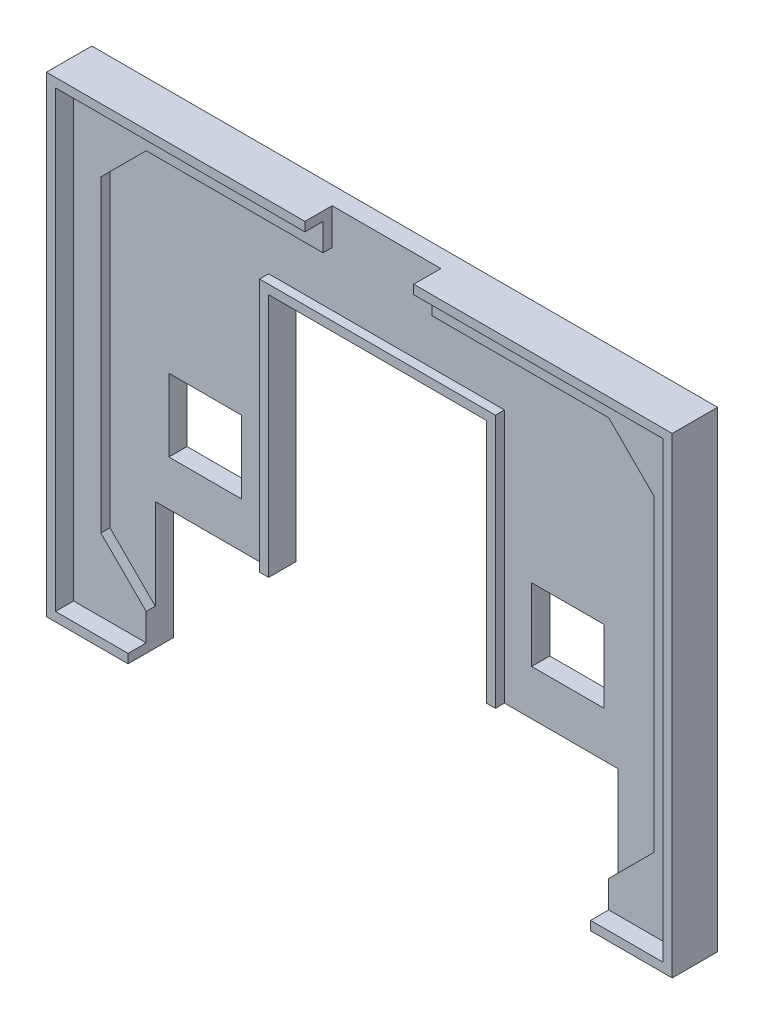
from build123d import *

# Parameters (mm, degrees)
SKICA1_W                    = 67
SKICA1_H                    = 50
P_IDAT_VYSUNUT_M1_DEPTH     = 3
ODEBRAT_VYSUNUT_M1_DEPTH    = 1
SKICA3_W                    = 8
SKICA3_H                    = 8
ODEBRAT_VYSUNUT_M2_DEPTH    = 4
VYSUNOUT_TENKOST_NN_1_DEPTH = 1
VYSUNOUT_TENKOST_NN_2_DEPTH = 5
SKICA6_W                    = 12
SKICA6_H                    = 4
ODEBRAT_VYSUNUT_M3_DEPTH    = 4
ODEBRAT_VYSUNUT_M4_DEPTH    = 1
P_IDAT_START                = -1
SKICA8_W                    = 0.8
SKICA8_H                    = 0.8
P_IDAT_VYSUNUT_M2_DEPTH     = 1
ODEBRAT_VYSUNUT_M5_DEPTH    = 1
SKICA10_W                   = 1.6
SKICA10_H                   = 2.4
P_IDAT_VYSUNUT_M3_DEPTH     = 1


with BuildPart() as part:
    # Skica1 → Přidat vysunutím1 (new body)
    with BuildSketch(Plane.XY):
        Rectangle(SKICA1_W, SKICA1_H)
    extrude(amount=P_IDAT_VYSUNUT_M1_DEPTH)

    # Skica2 → Odebrat vysunutím1 (cut)
    with BuildSketch(Plane.XY.offset(3)):
        Polygon((-25.5, -22), (-30.5, -17), (-30.5, 17), (-25.5, 22), (25.5, 22), (30.5, 17), (30.5, -17), (25.5, -22), align=None)
    extrude(amount=-ODEBRAT_VYSUNUT_M1_DEPTH, mode=Mode.SUBTRACT)

    # Skica3 → Odebrat vysunutím2 (cut, through all)
    with BuildSketch(Plane(origin=(0, 0, 0), x_dir=(-1, 0, 0), z_dir=(0, 0, -1))):
        with Locations((20, -3)):
            Rectangle(SKICA3_W, SKICA3_H)
        with Locations((-20, -3)):
            Rectangle(SKICA3_W, SKICA3_H)
        Polygon((25.5, -25), (-25.5, -25), (-25.5, -12), (-12, -12), (-12, 15), (12, 15), (12, -12), (25.5, -12), align=None)
    extrude(amount=-ODEBRAT_VYSUNUT_M2_DEPTH, mode=Mode.SUBTRACT)

    # Skica4 → Vysunout tenkostěnný1 (add)
    with BuildSketch(Plane.XY.offset(2)):
        Polygon((-12, -12), (-12, 15), (12, 15), (12, -12), (13, -12), (13, 16), (-13, 16), (-13, -12), align=None)
    extrude(amount=VYSUNOUT_TENKOST_NN_1_DEPTH)

    # Skica5 → Vysunout tenkostěnný2 (add)
    with BuildSketch(Plane(origin=(0, 0, 0), x_dir=(-1, 0, 0), z_dir=(0, 0, -1))):
        Polygon((-25.5, -25), (-33.5, -25), (-33.5, 25), (33.5, 25), (33.5, -25), (25.5, -25), (25.5, -26), (34.5, -26), (34.5, 26), (-34.5, 26), (-34.5, -26), (-25.5, -26), align=None)
    extrude(amount=-VYSUNOUT_TENKOST_NN_2_DEPTH)

    # Skica6 → Odebrat vysunutím3 (cut, through all)
    with BuildSketch(Plane.XY.offset(2)):
        with Locations((0, 24)):
            Rectangle(SKICA6_W, SKICA6_H)
    extrude(amount=ODEBRAT_VYSUNUT_M3_DEPTH, mode=Mode.SUBTRACT)

    # Skica7 → Odebrat vysunutím4 (cut)
    with BuildSketch(Plane(origin=(0, 0, 0), x_dir=(-1, 0, 0), z_dir=(0, 0, -1))):
        Polygon((-26, 19.6), (-20.5, 19.6), (-20.5, 20.4), (-18.9, 20.4), (-18.9, 21.2), (-18.1, 21.2), (-18.1, 22), (-14.9, 22), (-14.9, 18.8), (-15.696848358, 18.8), (-15.696848358, 17.2), (-16.496848358, 17.2), (-16.496848358, 15.6), (-15.696848358, 15.6), (-15.696848358, 14), (-14.896848358, 14), (-14.896848358, 11.6), (-15.696848358, 11.6), (-15.696848358, 10), (-16.496848358, 10), (-16.496848358, 9.2), (-17.3, 9.2), (-17.3, 8.4), (-18.1, 8.4), (-18.1, 7.6), (-18.9, 7.6), (-18.9, 6.8), (-20.5, 6.8), (-20.5, 6), (-26, 6), (-26, 6.8), (-27.6, 6.8), (-27.6, 7.6), (-28.4, 7.6), (-28.4, 8.4), (-29.2, 8.4), (-29.2, 9.2), (-30, 9.2), (-30, 10), (-30.8, 10), (-30.8, 11.6), (-31.6, 11.6), (-31.6, 14), (-30.8, 14), (-30.8, 15.6), (-30, 15.6), (-30, 17.2), (-30.8, 17.2), (-30.8, 18.8), (-31.6, 18.8), (-31.6, 22), (-28.4, 22), (-28.4, 21.2), (-27.6, 21.2), (-27.6, 20.4), (-26, 20.4), align=None)
        Polygon((27.6, 20.4), (26, 20.4), (26, 19.6), (20.5, 19.6), (20.5, 20.4), (18.9, 20.4), (18.9, 21.2), (18.1, 21.2), (18.1, 22), (14.9, 22), (14.9, 18.8), (15.696848358, 18.8), (15.696848358, 17.2), (16.496848358, 17.2), (16.496848358, 15.6), (15.696848358, 15.6), (15.696848358, 14), (14.896848358, 14), (14.896848358, 11.6), (15.696848358, 11.6), (15.696848358, 10), (16.496848358, 10), (16.496848358, 9.2), (17.3, 9.2), (17.3, 8.4), (18.1, 8.4), (18.1, 7.6), (18.9, 7.6), (18.9, 6.8), (20.5, 6.8), (20.5, 6), (26, 6), (26, 6.8), (27.6, 6.8), (27.6, 7.6), (28.4, 7.6), (28.4, 8.4), (29.2, 8.4), (29.2, 9.2), (30, 9.2), (30, 10), (30.8, 10), (30.8, 11.6), (31.6, 11.6), (31.6, 14), (30.8, 14), (30.8, 15.6), (30, 15.6), (30, 17.2), (30.8, 17.2), (30.8, 18.8), (31.6, 18.8), (31.6, 22), (28.4, 22), (28.4, 21.2), (27.6, 21.2), align=None)
    extrude(amount=-ODEBRAT_VYSUNUT_M4_DEPTH, mode=Mode.SUBTRACT)

    # Skica8 → Přidat vysunutím2 (add)
    with BuildSketch(Plane(origin=(0, 0, 0), x_dir=(-1, 0, 0), z_dir=(0, 0, -1)).offset(P_IDAT_START)):
        Polygon((-27.6, 15.6), (-26.8, 15.6), (-26.8, 14.8), (-26, 14.8), (-26, 15.6), (-25.2, 15.6), (-25.2, 14), (-27.6, 14), align=None)
        Polygon((-21.3, 14), (-18.9, 14), (-18.9, 15.6), (-19.7, 15.6), (-19.7, 14.8), (-20.5, 14.8), (-20.5, 15.6), (-21.3, 15.6), align=None)
        Polygon((-22.05, 13.2), (-24.45, 13.2), (-24.45, 12.4), (-23.65, 12.4), (-23.65, 10), (-25.25, 10), (-25.25, 9.2), (-24.45, 9.2), (-24.45, 8.4), (-23.65, 8.4), (-23.65, 7.6), (-22.85, 7.6), (-22.85, 8.4), (-22.05, 8.4), (-22.05, 9.2), (-21.25, 9.2), (-21.25, 10), (-22.85, 10), (-22.85, 12.4), (-22.05, 12.4), align=None)
        with Locations((-20.849, 10.401)):
            Rectangle(SKICA8_W, SKICA8_H)
        with Locations((-25.651, 10.401)):
            Rectangle(SKICA8_W, SKICA8_H)
        with Locations((25.651, 10.401)):
            Rectangle(SKICA8_W, SKICA8_H)
        with Locations((20.849, 10.401)):
            Rectangle(SKICA8_W, SKICA8_H)
        Polygon((22.05, 12.4), (22.05, 13.2), (24.45, 13.2), (24.45, 12.4), (23.65, 12.4), (23.65, 10), (25.25, 10), (25.25, 9.2), (24.45, 9.2), (24.45, 8.4), (23.65, 8.4), (23.65, 7.6), (22.85, 7.6), (22.85, 8.4), (22.05, 8.4), (22.05, 9.2), (21.25, 9.2), (21.25, 10), (22.85, 10), (22.85, 12.4), align=None)
        Polygon((21.3, 15.6), (21.3, 14), (18.9, 14), (18.9, 15.6), (19.7, 15.6), (19.7, 14.8), (20.5, 14.8), (20.5, 15.6), align=None)
        Polygon((25.2, 14), (27.6, 14), (27.6, 15.6), (26.8, 15.6), (26.8, 14.8), (26, 14.8), (26, 15.6), (25.2, 15.6), align=None)
    extrude(amount=P_IDAT_VYSUNUT_M2_DEPTH)

    # Skica9 → Odebrat vysunutím5 (cut)
    with BuildSketch(Plane(origin=(0, 0, 0), x_dir=(-1, 0, 0), z_dir=(0, 0, -1))):
        Polygon((-10.5, 23.3), (-5.7, 23.3), (-5.7, 22.1), (-8.9, 22.1), (-8.9, 20.9), (-6.5, 20.9), (-6.5, 19.7), (-8.9, 19.7), (-8.9, 17.7), (-10.5, 17.7), align=None)
        Polygon((-4.1, 23.3), (-0.9, 23.3), (-0.9, 22.5), (-0.1, 22.5), (-0.1, 18.5), (-0.9, 18.5), (-0.9, 17.7), (-4.1, 17.7), (-4.1, 18.5), (-4.9, 18.5), (-4.9, 22.5), (-4.1, 22.5), align=None)
        Polygon((0.894507814, 23.3), (2.494507814, 23.3), (2.494507814, 21.7), (3.094507814, 21.7), (3.094507814, 20.9), (3.496679315, 20.9), (3.496679315, 21.7), (4.099936566, 21.7), (4.099936566, 23.3), (5.699936566, 23.3), (5.699936566, 21.7), (5.099936566, 21.7), (5.099936566, 20.9), (4.499936566, 20.9), (4.499936566, 20.1), (5.099936566, 20.1), (5.099936566, 19.3), (5.699936566, 19.3), (5.699936566, 17.7), (4.099936566, 17.7), (4.099936566, 19.3), (3.496679315, 19.3), (3.496679315, 20.1), (3.094507814, 20.1), (3.094507814, 19.3), (2.494507814, 19.3), (2.494507814, 17.7), (0.894507814, 17.7), (0.894507814, 19.3), (1.494507814, 19.3), (1.494507814, 20.1), (2.094507814, 20.1), (2.094507814, 20.9), (1.494507814, 20.9), (1.494507814, 21.7), (0.894507814, 21.7), align=None)
        Polygon((6.499936566, 23.3), (10.499936566, 23.3), (10.499936566, 22.3), (9.299936566, 22.3), (9.299936566, 18.7), (10.499936566, 18.7), (10.499936566, 17.7), (6.499936566, 17.7), (6.499936566, 18.7), (7.699936566, 18.7), (7.699936566, 22.3), (6.499936566, 22.3), align=None)
    extrude(amount=-ODEBRAT_VYSUNUT_M5_DEPTH, mode=Mode.SUBTRACT)

    # Skica10 → Přidat vysunutím3 (add)
    with BuildSketch(Plane(origin=(0, 0, 1), x_dir=(-1, 0, 0), z_dir=(0, 0, -1))):
        with Locations((-2.5, 20.5)):
            Rectangle(SKICA10_W, SKICA10_H)
    extrude(amount=P_IDAT_VYSUNUT_M3_DEPTH)


solid = part.part
